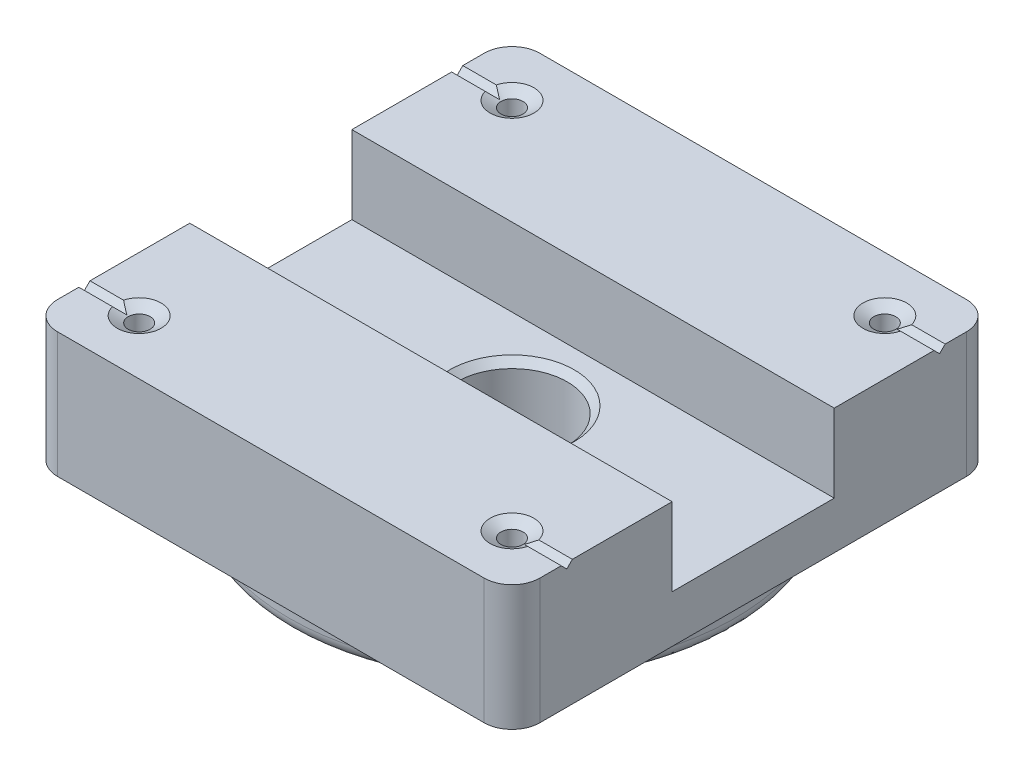
from build123d import *

# Parameters (mm, degrees)
SKETCH1_W                         = 43.9928
SKETCH1_H                         = 43.9928
EXTRUDE1_DEPTH                    = 11.43
M2X0_4_TAPPED_HOLE1_AT_2_COUNT    = 2
M2X0_4_TAPPED_HOLE1_AT_2_PITCH    = 34
M2X0_4_TAPPED_HOLE1_AT_3_COUNT    = 2
M2X0_4_TAPPED_HOLE1_AT_3_PITCH    = 48.083261121
M2X0_4_TAPPED_HOLE1_AT_4_COUNT    = 2
M2X0_4_TAPPED_HOLE1_AT_4_PITCH    = 34
FILLET1_R                         = 2.54
FILLET2_R                         = 0.762
FILLET3_R                         = 1.27
SKETCH8_W                         = 43.9928
SKETCH8_H                         = 14.7828
CUT_EXTRUDE1_DEPTH                = 7.112
F_3_8_CLEARANCE_HOLE1_D           = 10.0838
F_3_8_CLEARANCE_HOLE1_CSINK_D     = 11.3538
F_3_8_CLEARANCE_HOLE1_CSINK_ANGLE = 90
CUT_EXTRUDE2_DEPTH                = 4.9964
FILLET4_R                         = 2.54


with BuildPart() as part:
    # Sketch1 → Extrude1 (new body)
    with BuildSketch(Plane(origin=(0, 0, 0), x_dir=(1, 0, 0), z_dir=(0, 1, 0))):
        Rectangle(SKETCH1_W, SKETCH1_H)
    extrude(amount=EXTRUDE1_DEPTH)

    # Sketch2 → M2x0.4 Tapped Hole1 (revolve, cut)
    with BuildSketch(Plane(origin=(-17, 11.43, -17), x_dir=(0, 0, 1), z_dir=(1, 0, 0))):
        Polygon((0, 0), (0, 11.43), (0.8, 11.43), (0.8, 8.001), (1, 8.001), (1, 0.577350269), (2, 0), align=None)
    m2x0_4_tapped_hole1 = revolve(axis=Axis((-17, 17.78, -17), (0, -1, 0)), mode=Mode.SUBTRACT)

    # M2x0.4 Tapped Hole1 at 2: M2x0.4 Tapped Hole1 ×2
    with Locations(*[(0, 0, i * M2X0_4_TAPPED_HOLE1_AT_2_PITCH) for i in range(1, M2X0_4_TAPPED_HOLE1_AT_2_COUNT)]):
        add(m2x0_4_tapped_hole1, mode=Mode.SUBTRACT)

    # M2x0.4 Tapped Hole1 at 3: M2x0.4 Tapped Hole1 ×2
    with Locations(*[Vector(0.707106781, 0, 0.707106781) * (i * M2X0_4_TAPPED_HOLE1_AT_3_PITCH) for i in range(1, M2X0_4_TAPPED_HOLE1_AT_3_COUNT)]):
        add(m2x0_4_tapped_hole1, mode=Mode.SUBTRACT)

    # M2x0.4 Tapped Hole1 at 4: M2x0.4 Tapped Hole1 ×2
    with Locations(*[(i * M2X0_4_TAPPED_HOLE1_AT_4_PITCH, 0, 0) for i in range(1, M2X0_4_TAPPED_HOLE1_AT_4_COUNT)]):
        add(m2x0_4_tapped_hole1, mode=Mode.SUBTRACT)

    # Fillet1
    fillet1_edges = [part.edges().sort_by_distance(p)[0] for p in [
        (-21.9964, 5.715, -21.9964),
        (21.9964, 5.715, -21.9964),
        (21.9964, 5.715, 21.9964),
        (-21.9964, 5.715, 21.9964),
    ]]
    fillet(fillet1_edges, radius=FILLET1_R)

    # Sketch5 → Revolve2 (revolve)
    with BuildSketch(Plane(origin=(0, 0, 0), x_dir=(0, 0, -1), z_dir=(1, 0, 0)), mode=Mode.PRIVATE) as revolve2_sk:
        with BuildLine():
            Line((-20.32, -3.018986953), (-20.32, 0))
            Line((-20.32, 0), (0, 0))
            Line((0, 0), (0, -7.903112155))
            Line((0, -7.903112155), (-8.615503825, -7.903112155))
            ThreePointArc((-8.615503825, -7.903112155), (-14.67240659, -5.951491505), (-20.32, -3.018986953))
        make_face()
    revolve(revolve2_sk.sketch.rotate(Axis((0, -19.634058574, 0), (0, 1, 0)), 180), axis=Axis((0, -19.634058574, 0), (0, 1, 0)))  # turned: the seam where the file's is

    # Fillet2
    fillet2_edges = [part.edges().sort_by_distance(p)[0] for p in [
        (0, 0, 20.32),
    ]]
    fillet(fillet2_edges, radius=FILLET2_R)

    # Fillet3
    fillet3_edges = [part.edges().sort_by_distance(p)[0] for p in [
        (0, -3.018986953, 20.32),
    ]]
    fillet(fillet3_edges, radius=FILLET3_R)

    # Sketch8 → Cut-Extrude1 (cut)
    with BuildSketch(Plane(origin=(0, 11.43, 0), x_dir=(1, 0, 0), z_dir=(0, 1, 0))):
        Rectangle(SKETCH8_W, SKETCH8_H)
    extrude(amount=-CUT_EXTRUDE1_DEPTH, mode=Mode.SUBTRACT)

    # 3/8 Clearance Hole1 (through all)
    with Locations(Plane(origin=(-2.697409808, 4.318, -0.911996033), x_dir=(-1, 0, 0), z_dir=(0, 1, 0))):
        with Locations((-2.697409808, 0.911996033)):
            CounterSinkHole(F_3_8_CLEARANCE_HOLE1_D / 2, F_3_8_CLEARANCE_HOLE1_CSINK_D / 2, counter_sink_angle=F_3_8_CLEARANCE_HOLE1_CSINK_ANGLE)

    # Sketch9 → Cut-Extrude2 (cut)
    with BuildSketch(Plane.ZY.offset(21.9964)):
        Polygon((-17.508, 11.43), (-17, 10.922), (-16.492, 11.43), align=None)
        Polygon((16.492, 11.43), (17, 10.922), (17.508, 11.43), align=None)
    cut_extrude2 = extrude(amount=-CUT_EXTRUDE2_DEPTH, mode=Mode.SUBTRACT)

    # Mirror1: Cut-Extrude2 across plane
    add(cut_extrude2.mirror(Plane(origin=(0, 0, 0), x_dir=(0, 0, 1), z_dir=(1, 0, 0))), mode=Mode.SUBTRACT)

    # Fillet4
    fillet4_edges = [part.edges().sort_by_distance(p)[0] for p in [
        (0, -7.903112155, 8.615503825),
    ]]
    fillet(fillet4_edges, radius=FILLET4_R)


solid = part.part
